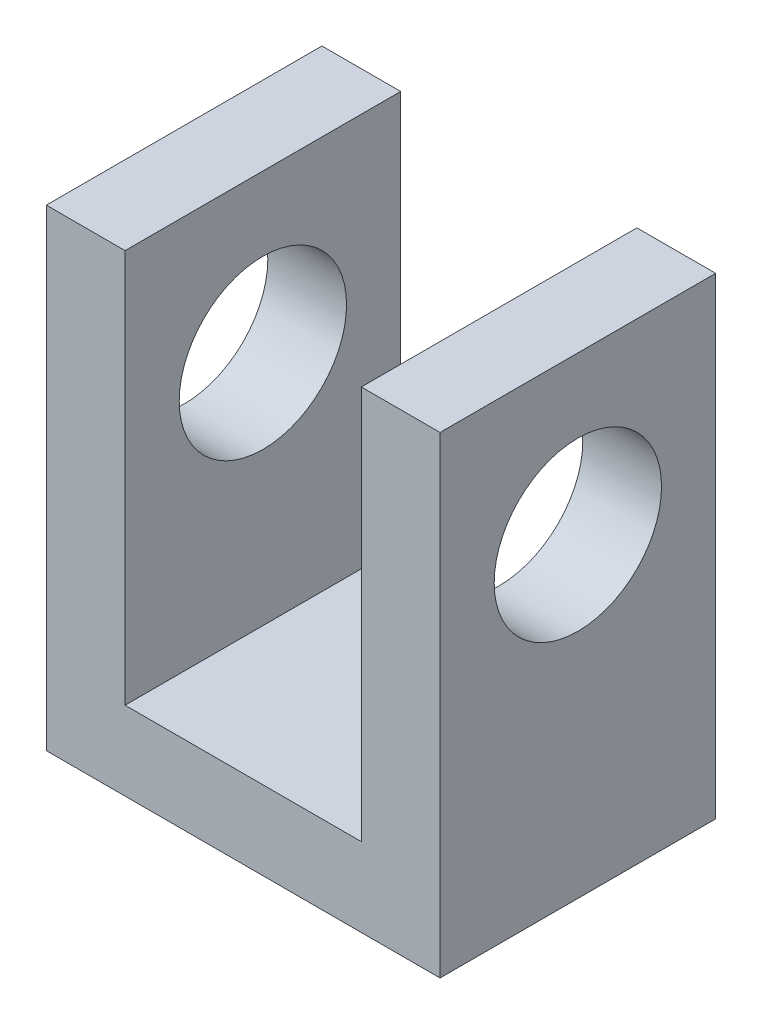
from build123d import *

# Parameters (mm, degrees)
SKETCH1_W           = 10
SKETCH1_H           = 7
BOSS_EXTRUDE1_DEPTH = 12
SKETCH2_W           = 3
SKETCH2_H           = 7
CUT_EXTRUDE1_DEPTH  = 10
SKETCH3_R           = 2.125
CUT_EXTRUDE2_DEPTH  = 11


with BuildPart() as part:
    # Sketch1 → Boss-Extrude1 (new body)
    with BuildSketch(Plane(origin=(0, 0, 0), x_dir=(1, 0, 0), z_dir=(0, 1, 0))):
        with Locations((5, 3.5)):
            Rectangle(SKETCH1_W, SKETCH1_H)
    extrude(amount=BOSS_EXTRUDE1_DEPTH)

    # Sketch2 → Cut-Extrude1 (cut)
    with BuildSketch(Plane(origin=(0, 12, 0), x_dir=(1, 0, 0), z_dir=(0, 1, 0))):
        with Locations((3.5, 3.5)):
            Rectangle(SKETCH2_W, SKETCH2_H)
        with Locations((6.5, 3.5)):
            Rectangle(SKETCH2_W, SKETCH2_H)
    extrude(amount=-CUT_EXTRUDE1_DEPTH, mode=Mode.SUBTRACT)

    # Sketch3 → Cut-Extrude2 (cut, through all)
    with BuildSketch(Plane(origin=(10, 0, 0), x_dir=(0, 0, -1), z_dir=(1, 0, 0))):
        with Locations((3.5, 8)):
            Circle(SKETCH3_R)
    extrude(amount=-CUT_EXTRUDE2_DEPTH, mode=Mode.SUBTRACT)


solid = part.part
